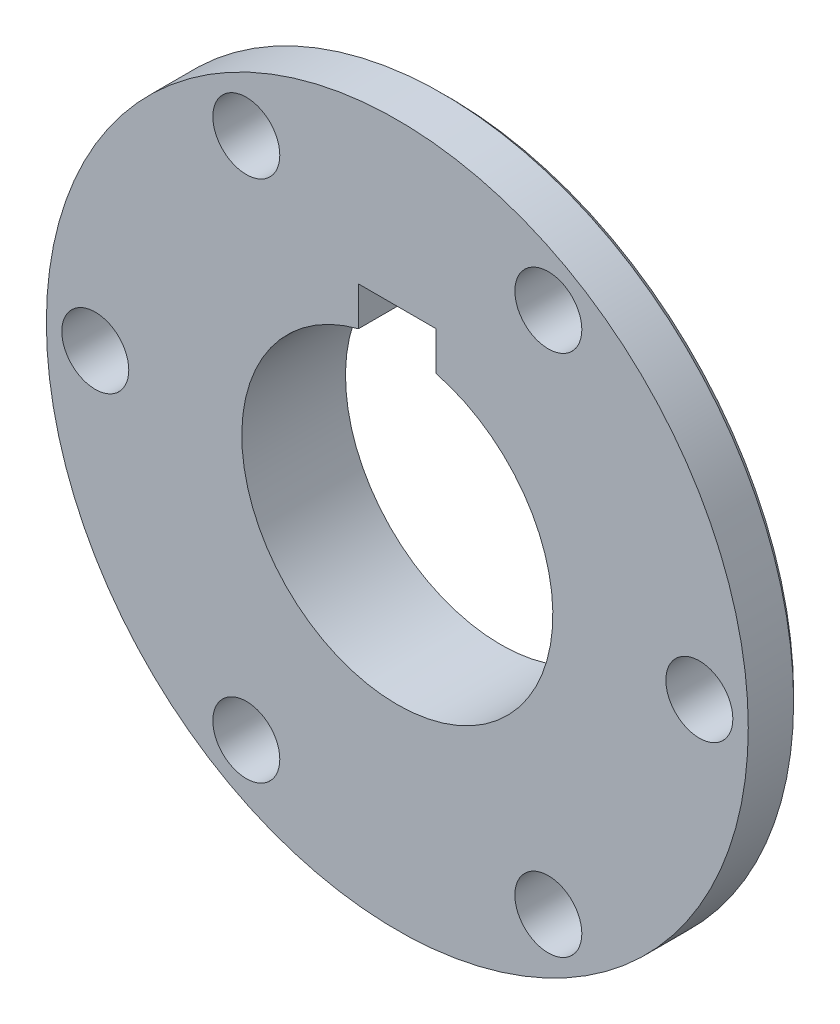
from build123d import *

# Parameters (mm, degrees)
SKETCH1_R           = 42.9895
BOSS_EXTRUDE1_DEPTH = 12.7
SKETCH2_R           = 4.1021
CUT_EXTRUDE1_DEPTH  = 13.7
SKETCH3_OUTSIDE_W   = 112.43
SKETCH3_OUTSIDE_H   = 112.43
SKETCH3_OUTSIDE_R   = 27.882207728
CUT_EXTRUDE2_DEPTH  = 6.35
CHAMFER1_SIZE       = 0.79375
CHAMFER2_SIZE       = 0.79375


with BuildPart() as part:
    # Sketch1 → Boss-Extrude1 (new body)
    with BuildSketch(Plane.XY):
        Circle(SKETCH1_R)
        with BuildLine():
            Line((-4.7625, 23.207583186), (-4.7625, 18.445083186))
            ThreePointArc((-4.7625, 18.445083186), (0, -19.05), (4.7625, 18.445083186))
            Line((4.7625, 18.445083186), (4.7625, 23.207583186))
            Line((4.7625, 23.207583186), (-4.7625, 23.207583186))
        make_face(mode=Mode.SUBTRACT)
    extrude(amount=BOSS_EXTRUDE1_DEPTH)

    # Sketch2 → Cut-Extrude1 (cut, through all)
    with BuildSketch(Plane.XY):
        with Locations((36.9951, 0)):
            Circle(SKETCH2_R)
        with Locations((18.49755, -32.038696425)):
            Circle(SKETCH2_R)
        with Locations((-18.49755, -32.038696425)):
            Circle(SKETCH2_R)
        with Locations((-36.9951, 0)):
            Circle(SKETCH2_R)
        with Locations((-18.49755, 32.038696425)):
            Circle(SKETCH2_R)
        with Locations((18.49755, 32.038696425)):
            Circle(SKETCH2_R)
    extrude(amount=CUT_EXTRUDE1_DEPTH, mode=Mode.SUBTRACT)

    # Sketch3 outside → Cut-Extrude2 (cut)
    with BuildSketch(Plane.XY):
        Rectangle(SKETCH3_OUTSIDE_W, SKETCH3_OUTSIDE_H)
        Circle(SKETCH3_OUTSIDE_R, mode=Mode.SUBTRACT)
    extrude(amount=CUT_EXTRUDE2_DEPTH, mode=Mode.SUBTRACT)

    # Chamfer1
    chamfer1_edges = [part.edges().sort_by_distance(p)[0] for p in [
        (-42.9895, 0, 6.35),
        (-27.882207728, 0, 0),
    ]]
    chamfer(chamfer1_edges, length=CHAMFER1_SIZE)

    # Chamfer2
    chamfer2_edges = [part.edges().sort_by_distance(p)[0] for p in [
        (-27.882207728, 0, 6.35),
    ]]
    chamfer(chamfer2_edges, length=CHAMFER2_SIZE)


solid = part.part
